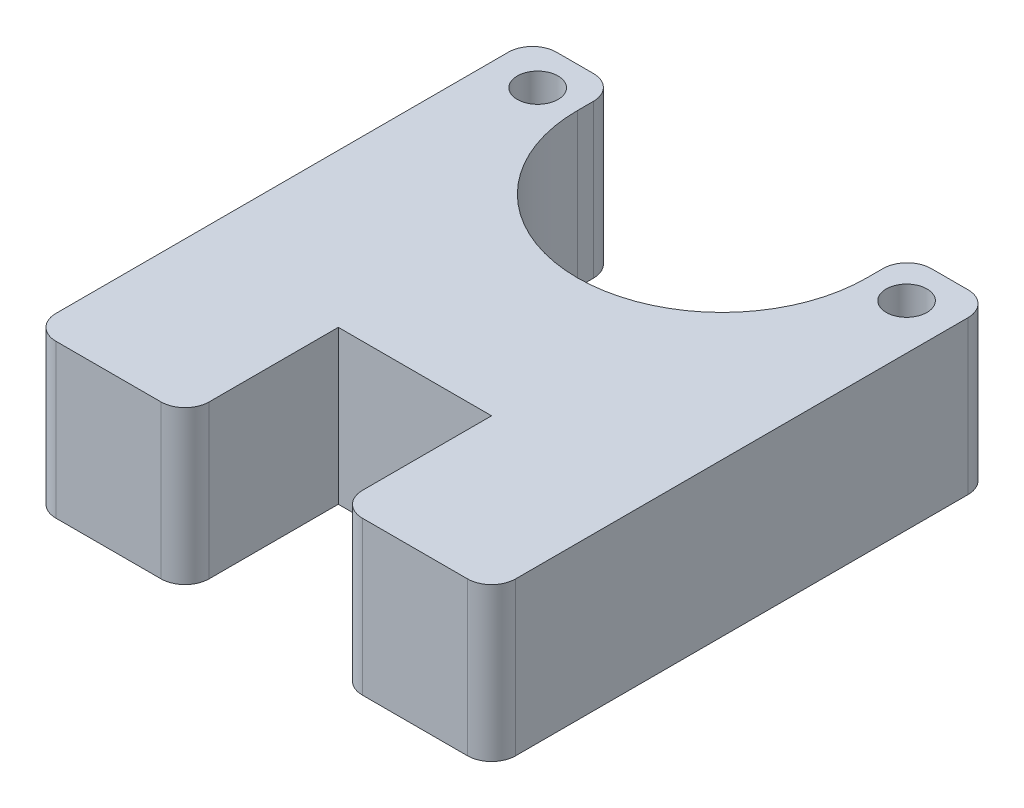
from build123d import *

# Parameters (mm, degrees)
SKETCH1_R           = 0.8449945
SKETCH1_W           = 19.05
SKETCH1_H           = 6.0000896
SKETCH1_W_2         = 6.35
SKETCH1_H_2         = 6.35
BOSS_EXTRUDE1_DEPTH = 6.35
FILLET3_R           = 1


with BuildPart() as part:
    # Sketch1 → Boss-Extrude1 (new body)
    with BuildSketch(Plane(origin=(0, 0, 0), x_dir=(1, 0, 0), z_dir=(0, 1, 0))):
        Polygon((0, 14.393729658), (0, 6.0000896), (3.5249993, 6.0000896), (3.5249993, 12.728734258), (3.5249993, 14.393729658), align=None)
        with Locations((1.88250068, 12.728734258)):
            Circle(SKETCH1_R, mode=Mode.SUBTRACT)
        with BuildLine():
            Line((3.5249993, 12.728734258), (3.5249993, 6.0000896))
            Line((3.5249993, 6.0000896), (15.5250007, 6.0000896))
            Line((15.5250007, 6.0000896), (15.5250007, 12.7287274))
            ThreePointArc((15.5250007, 12.7287274), (9.524996571, 6.7287267), (3.5249993, 12.728734258))
        make_face()
        Polygon((15.5250007, 12.7287274), (15.5250007, 6.0000896), (19.05, 6.0000896), (19.05, 14.393729658), (15.5250007, 14.393729658), align=None)
        with Locations((17.16749932, 12.7287274)):
            Circle(SKETCH1_R, mode=Mode.SUBTRACT)
        with Locations((9.525, 3.0000448)):
            Rectangle(SKETCH1_W, SKETCH1_H)
        with Locations((3.175, -3.175)):
            Rectangle(SKETCH1_W_2, SKETCH1_H_2)
        with Locations((15.875, -3.175)):
            Rectangle(SKETCH1_W_2, SKETCH1_H_2)
    extrude(amount=BOSS_EXTRUDE1_DEPTH)

    # Fillet3
    fillet3_edges = [part.edges().sort_by_distance(p)[0] for p in [
        (19.05, 3.175, 6.35),
        (12.7, 3.175, 6.35),
        (6.35, 3.175, 6.35),
        (0, 3.175, 6.35),
        (0, 3.175, -14.393729658),
        (3.5249993, 3.175, -14.393729658),
        (15.5250007, 3.175, -14.393729658),
        (19.05, 3.175, -14.393729658),
    ]]
    fillet(fillet3_edges, radius=FILLET3_R)


solid = part.part
